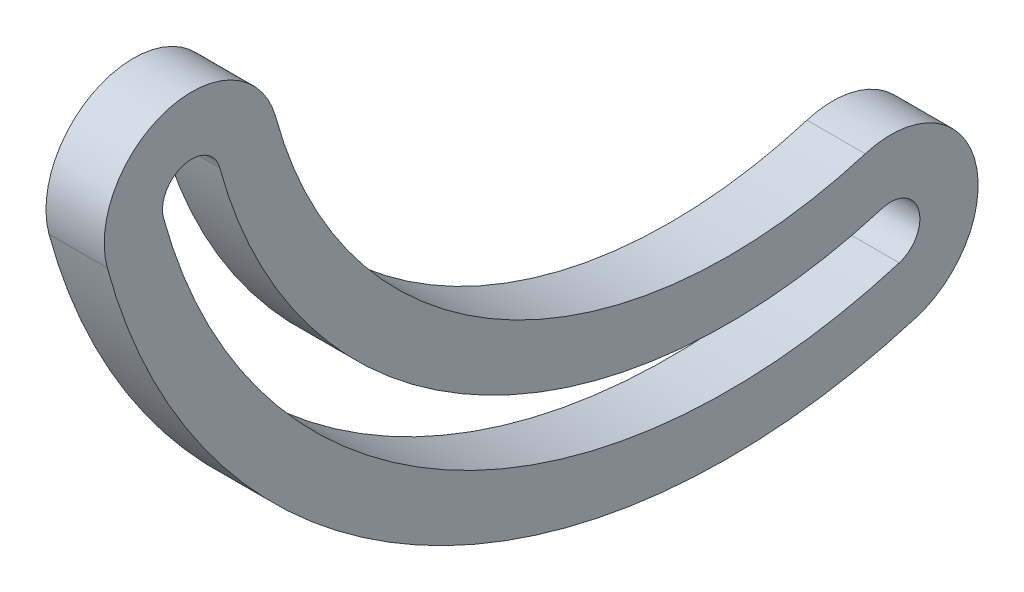
from build123d import *

# Parameters (mm, degrees)
BOSS_EXTRUDE1_DEPTH = 6.35


with BuildPart() as part:
    # Sketch2 → Boss-Extrude1 (new body)
    with BuildSketch(Plane(origin=(0, 0, 0), x_dir=(0, 0, -1), z_dir=(1, 0, 0))):
        with BuildLine():
            ThreePointArc((-9.192931445, -2.493117818), (24.571747116, -45.532400085), (78.974839391, -51.254015886))
            ThreePointArc((78.974839391, -51.254015886), (85.311854441, -39.367322054), (73.425160609, -33.030307004))
            ThreePointArc((73.425160609, -33.030307004), (33.791268801, -28.861979578), (9.192931445, 2.493117818))
            ThreePointArc((9.192931445, 2.493117818), (-2.493117818, 9.192931445), (-9.192931445, -2.493117818))
        make_face()
        with BuildLine():
            ThreePointArc((-3.064310482, -0.831039273), (27.644921011, -39.975593249), (77.124946464, -45.179446258))
            ThreePointArc((77.124946464, -45.179446258), (79.237284814, -41.217214981), (75.275053536, -39.104876631))
            ThreePointArc((75.275053536, -39.104876631), (30.718094906, -34.418786414), (3.064310482, 0.831039273))
            ThreePointArc((3.064310482, 0.831039273), (-0.831039273, 3.064310482), (-3.064310482, -0.831039273))
        make_face(mode=Mode.SUBTRACT)
    extrude(amount=BOSS_EXTRUDE1_DEPTH)


solid = part.part
